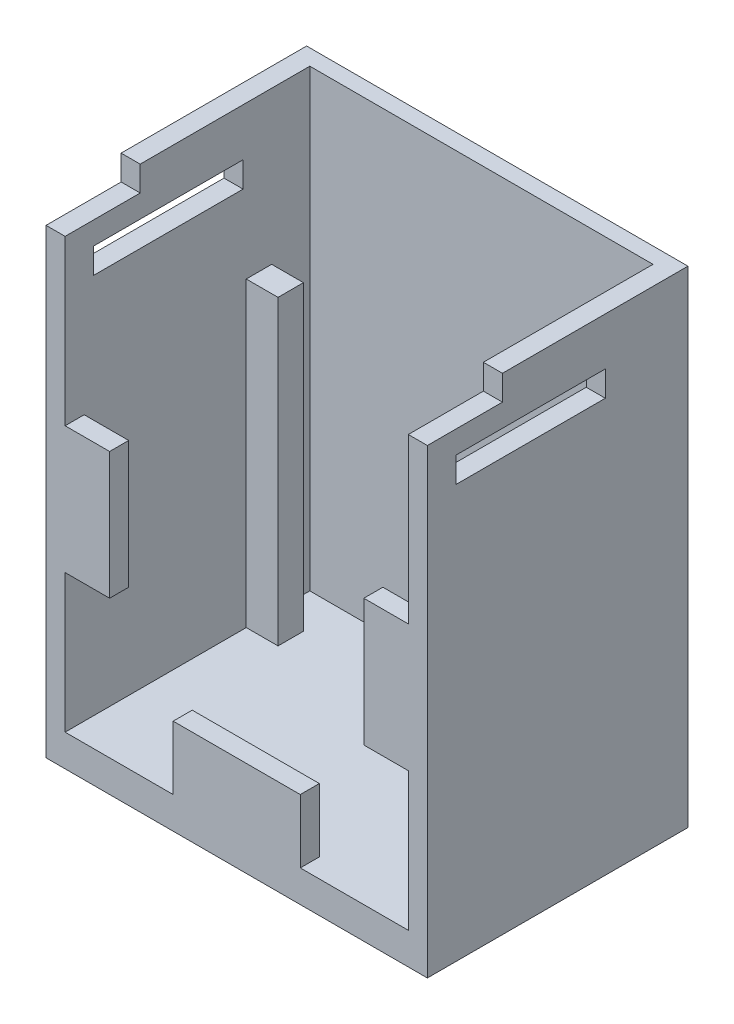
from build123d import *

# Parameters (mm, degrees)
SKETCH1_W                = 30.48
SKETCH1_H                = 40.64
INITIAL_BLOCK_DEPTH      = 19.05
INITIAL_BLOCK_DEPTH_BACK = 1.778
SKETCH2_W                = 27.432
SKETCH2_H                = 19.558
INITIAL_CUT_DEPTH        = 38.1
SKETCH20_W               = 5.08
SKETCH20_H               = 10.16
SKETCH20_W_2             = 10.16
SKETCH20_H_2             = 5.08
BOSS_EXTRUDE1_DEPTH      = 1.524
SKETCH21_W               = 2.032
SKETCH21_H               = 24.13
BOSS_EXTRUDE2_DEPTH      = 2.54
SKETCH27_W               = 11.938
SKETCH27_H               = 2.032
CUT_EXTRUDE6_DEPTH       = 1.524
SKETCH28_W               = 30.48
SKETCH28_H               = 1.778
CUT_EXTRUDE7_DEPTH       = 21.828
SKETCH29_W               = 30.48
SKETCH29_H               = 2
CUT_EXTRUDE8_DEPTH       = 6


with BuildPart() as part:
    # Sketch1 → Initial Block (new body, two sides)
    with BuildSketch(Plane.XY) as initial_block_sk:
        with Locations((0, -5.08)):
            Rectangle(SKETCH1_W, SKETCH1_H)
    extrude(amount=INITIAL_BLOCK_DEPTH)
    extrude(initial_block_sk.sketch, amount=-INITIAL_BLOCK_DEPTH_BACK)

    # Sketch2 → Initial Cut (cut)
    with BuildSketch(Plane(origin=(0, 15.24, 0), x_dir=(1, 0, 0), z_dir=(0, 1, 0))):
        with Locations((0, -9.271)):
            Rectangle(SKETCH2_W, SKETCH2_H)
    extrude(amount=-INITIAL_CUT_DEPTH, mode=Mode.SUBTRACT)

    # Sketch20 → Boss-Extrude1 (add)
    with BuildSketch(Plane.XY.offset(19.05)):
        with Locations((-12.7, -6.731)):
            Rectangle(SKETCH20_W, SKETCH20_H)
        with Locations((12.7, -6.731)):
            Rectangle(SKETCH20_W, SKETCH20_H)
        with Locations((0, -20.32)):
            Rectangle(SKETCH20_W_2, SKETCH20_H_2)
    extrude(amount=-BOSS_EXTRUDE1_DEPTH)

    # Sketch21 → Boss-Extrude2 (add)
    with BuildSketch(Plane(origin=(-13.716, 0, 0), x_dir=(0, 0, -1), z_dir=(1, 0, 0))):
        with Locations((-3.556, -10.795)):
            Rectangle(SKETCH21_W, SKETCH21_H)
    boss_extrude2 = extrude(amount=BOSS_EXTRUDE2_DEPTH)

    # Mirror2: Boss-Extrude2 across plane
    add(boss_extrude2.mirror(Plane(origin=(0, 0, 0), x_dir=(0, 0, 1), z_dir=(1, 0, 0))))

    # Sketch27 → Cut-Extrude6 (cut)
    with BuildSketch(Plane(origin=(15.24, 0, 0), x_dir=(0, 0, -1), z_dir=(1, 0, 0))):
        with Locations((-10.795, 8.636)):
            Rectangle(SKETCH27_W, SKETCH27_H)
    cut_extrude6 = extrude(amount=-CUT_EXTRUDE6_DEPTH, mode=Mode.SUBTRACT)

    # Mirror6: Cut-Extrude6 across plane
    add(cut_extrude6.mirror(Plane(origin=(0, 0, 0), x_dir=(0, 0, 1), z_dir=(1, 0, 0))), mode=Mode.SUBTRACT)

    # Sketch28 → Cut-Extrude7 (cut, through all)
    with BuildSketch(Plane.XY.offset(19.05)):
        with Locations((0, 14.351)):
            Rectangle(SKETCH28_W, SKETCH28_H)
    extrude(amount=-CUT_EXTRUDE7_DEPTH, mode=Mode.SUBTRACT)

    # Sketch29 → Cut-Extrude8 (cut)
    with BuildSketch(Plane.XY.offset(19.05)):
        with Locations((0, 12.462)):
            Rectangle(SKETCH29_W, SKETCH29_H)
    extrude(amount=-CUT_EXTRUDE8_DEPTH, mode=Mode.SUBTRACT)


solid = part.part
